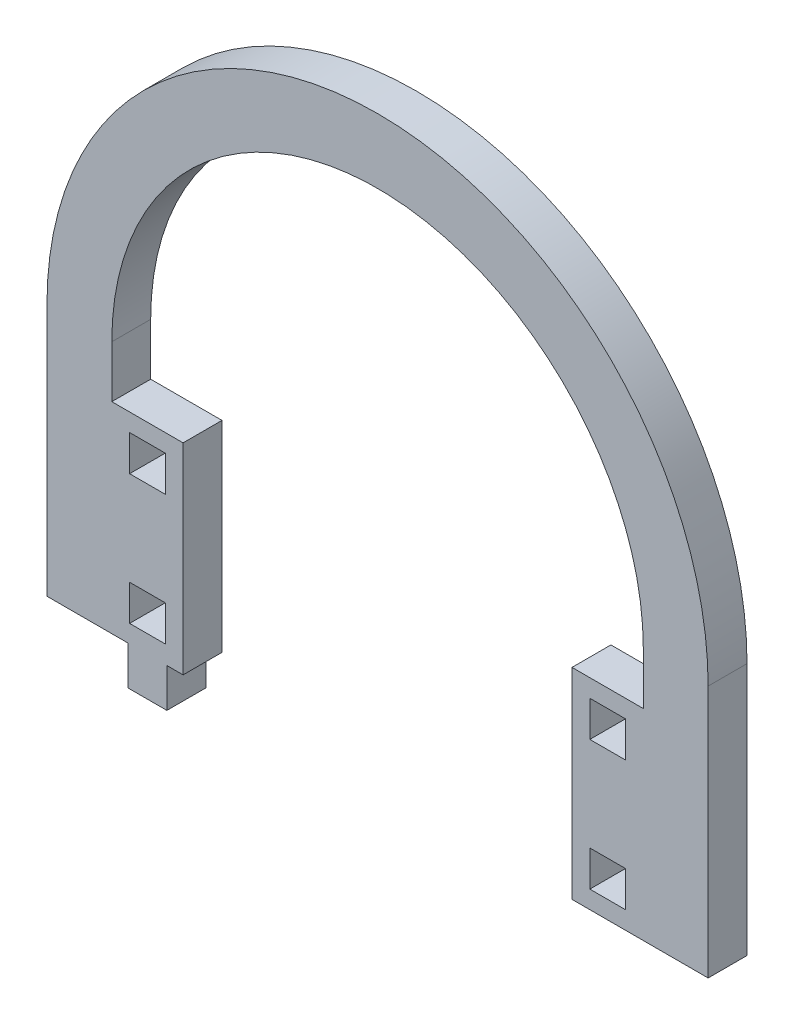
from build123d import *

# Parameters (mm, degrees)
MODEL_W             = 5.5
MODEL_H             = 5.5
BOSS_EXTRUDE1_DEPTH = 6


with BuildPart() as part:
    # Model → Boss-Extrude1 (new body)
    with BuildSketch(Plane.XY):
        with BuildLine():
            Line((2982.612369189, 1260.808846123), (2982.612369189, 1221.808846123))
            Line((2982.612369189, 1221.808846123), (2995.112369189, 1221.808846123))
            Line((2995.112369189, 1221.808846123), (2995.112369189, 1215.808846123))
            Line((2995.112369189, 1215.808846123), (3001.112369189, 1215.808846123))
            Line((3001.112369189, 1215.808846123), (3001.112369189, 1221.808846123))
            Line((3001.112369189, 1221.808846123), (3003.612369189, 1221.808846123))
            Line((3003.612369189, 1221.808846123), (3003.612369189, 1252.808846123))
            Line((3003.612369189, 1252.808846123), (2992.612369189, 1252.808846123))
            Line((2992.612369189, 1252.808846123), (2992.612369189, 1260.808846123))
            ThreePointArc((2992.612369189, 1260.808846123), (3033.612369189, 1301.808846123), (3074.612369189, 1260.808846123))
            Line((3074.612369189, 1260.808846123), (3074.612369189, 1252.808846123))
            Line((3074.612369189, 1252.808846123), (3063.612369189, 1252.808846123))
            Line((3063.612369189, 1252.808846123), (3063.612369189, 1221.808846123))
            Line((3063.612369189, 1221.808846123), (3074.612369189, 1221.808846123))
            Line((3074.612369189, 1221.808846123), (3084.612369189, 1221.808846123))
            Line((3084.612369189, 1221.808846123), (3084.612369189, 1260.808846123))
            ThreePointArc((3084.612369189, 1260.808846123), (3033.612369189, 1311.808846123), (2982.612369189, 1260.808846123))
        make_face()
        with Locations((3069.112369189, 1227.308846123)):
            Rectangle(MODEL_W, MODEL_H, mode=Mode.SUBTRACT)
        with Locations((3069.112369189, 1247.308846123)):
            Rectangle(MODEL_W, MODEL_H, mode=Mode.SUBTRACT)
        with Locations((2998.112369189, 1227.308846123)):
            Rectangle(MODEL_W, MODEL_H, mode=Mode.SUBTRACT)
        with Locations((2998.112369189, 1247.308846123)):
            Rectangle(MODEL_W, MODEL_H, mode=Mode.SUBTRACT)
    extrude(amount=BOSS_EXTRUDE1_DEPTH)


solid = part.part
